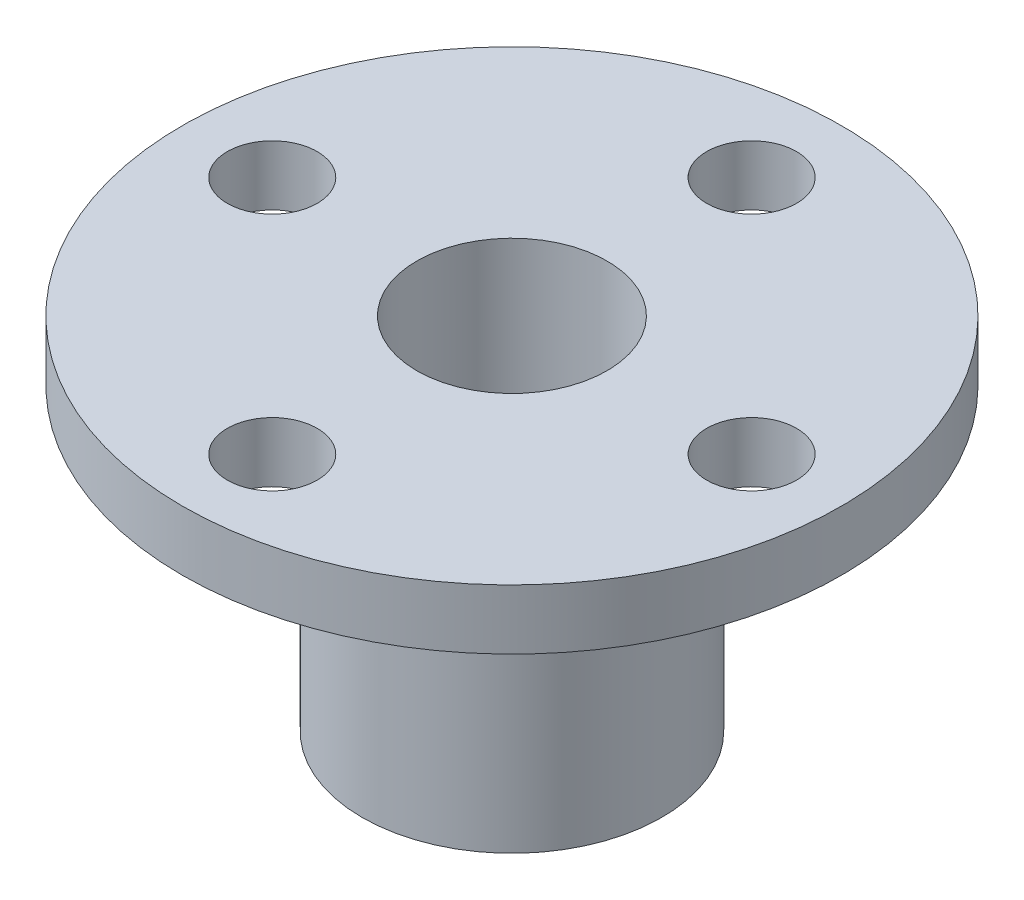
from build123d import *

# Parameters (mm, degrees)
SKETCH1_R           = 5
SKETCH1_R_2         = 3.175
BOSS_EXTRUDE1_DEPTH = 12
BOSS_EXTRUDE2_START = -2.000000064
SKETCH2_R           = 11
SKETCH2_R_2         = 3.175
BOSS_EXTRUDE2_DEPTH = 2.000000064
SKETCH3_R           = 1.5
CUT_EXTRUDE1_DEPTH  = 20.646882704
CUT_EXTRUDE2_DEPTH  = 20.646882704


with BuildPart() as part:
    # Sketch1 → Boss-Extrude1 (new body)
    with BuildSketch(Plane(origin=(0, 0, 0), x_dir=(1, 0, 0), z_dir=(0, 1, 0))):
        Circle(SKETCH1_R)
        Circle(SKETCH1_R_2, mode=Mode.SUBTRACT)
    extrude(amount=BOSS_EXTRUDE1_DEPTH)

    # Sketch2 → Boss-Extrude2 (add)
    with BuildSketch(Plane(origin=(0, 12, 0), x_dir=(1, 0, 0), z_dir=(0, 1, 0)).offset(BOSS_EXTRUDE2_START)):
        Circle(SKETCH2_R)
        Circle(SKETCH2_R_2, mode=Mode.SUBTRACT)
    extrude(amount=BOSS_EXTRUDE2_DEPTH)

    # Sketch3 → Cut-Extrude1 (cut, through all)
    with BuildSketch(Plane(origin=(0, 12, 0), x_dir=(1, 0, 0), z_dir=(0, 1, 0))):
        with Locations((0, 8)):
            Circle(SKETCH3_R)
        with Locations((8, 0)):
            Circle(SKETCH3_R)
        with Locations((0, -8)):
            Circle(SKETCH3_R)
        with Locations((-8, 0)):
            Circle(SKETCH3_R)
    extrude(amount=-CUT_EXTRUDE1_DEPTH, mode=Mode.SUBTRACT)

    # Sketch4 → Cut-Extrude2 (cut, through all)
    with BuildSketch(Plane(origin=(0, 0, 0), x_dir=(0, 1, 0), z_dir=(0.7071067811865464, 0, 0.7071067811865488))):
        with BuildLine():
            ThreePointArc((2.000000064, 0), (3.500000112, -1.500000048), (5.00000016, 0))
            ThreePointArc((5.00000016, 0), (3.500000112, 1.500000048), (2.000000064, 0))
        make_face()
    extrude(amount=-CUT_EXTRUDE2_DEPTH, mode=Mode.SUBTRACT)


solid = part.part
